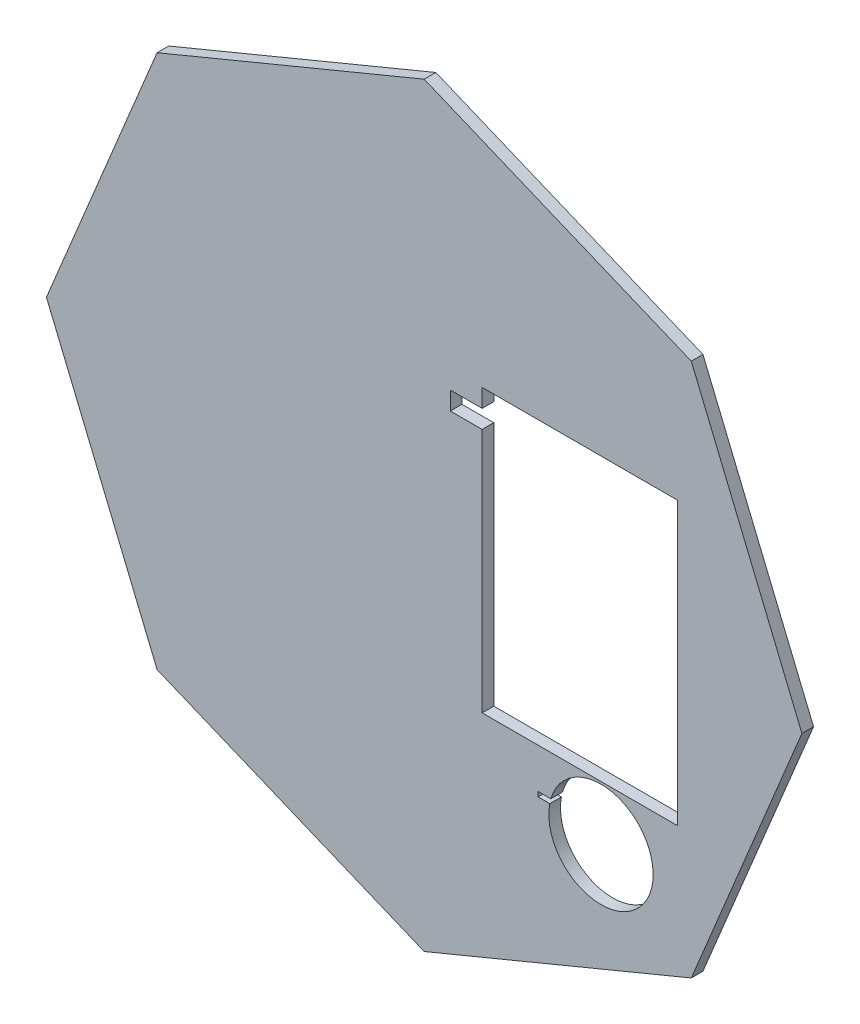
from build123d import *

# Parameters (mm, degrees)
BOSS_EXTRU_2_DEPTH = 1.3


with BuildPart() as part:
    # Esquisse2 → Boss.-Extru.2 (new body)
    with BuildSketch(Plane(origin=(0, 0, 14.509966587), x_dir=(-1, 0, 0), z_dir=(0, 0, -1))):
        Polygon((-55.223785445, -31.352276986), (-25.374778792, -43.716279214), (4.474220231, -31.352276986), (16.838222459, -1.503277963), (4.474220231, 28.345721061), (-25.374778792, 40.709719474), (-55.223785445, 28.345721061), (-67.587783858, -1.503277963), align=None)
        Polygon((-31.851776167, 10.053721244), (-31.851776167, -17.378277963), (-53.695785567, -17.378277963), (-53.695785567, 14.117724234), (-31.851776167, 14.117724234), (-31.851776167, 12.085718924), (-28.295776412, 12.085718924), (-28.295776412, 10.053721244), align=None, mode=Mode.SUBTRACT)
        with BuildLine():
            Line((-38.101776167, -21.860276406), (-39.529126769, -21.860276406))
            ThreePointArc((-39.529126769, -21.860276406), (-50.80118854, -24.813312469), (-39.4045428, -22.385089985))
            Line((-39.4045428, -22.385089985), (-38.101776167, -22.385089985))
            Line((-38.101776167, -22.385089985), (-38.101776167, -21.860276406))
        make_face(mode=Mode.SUBTRACT)
    extrude(amount=BOSS_EXTRU_2_DEPTH)


solid = part.part
